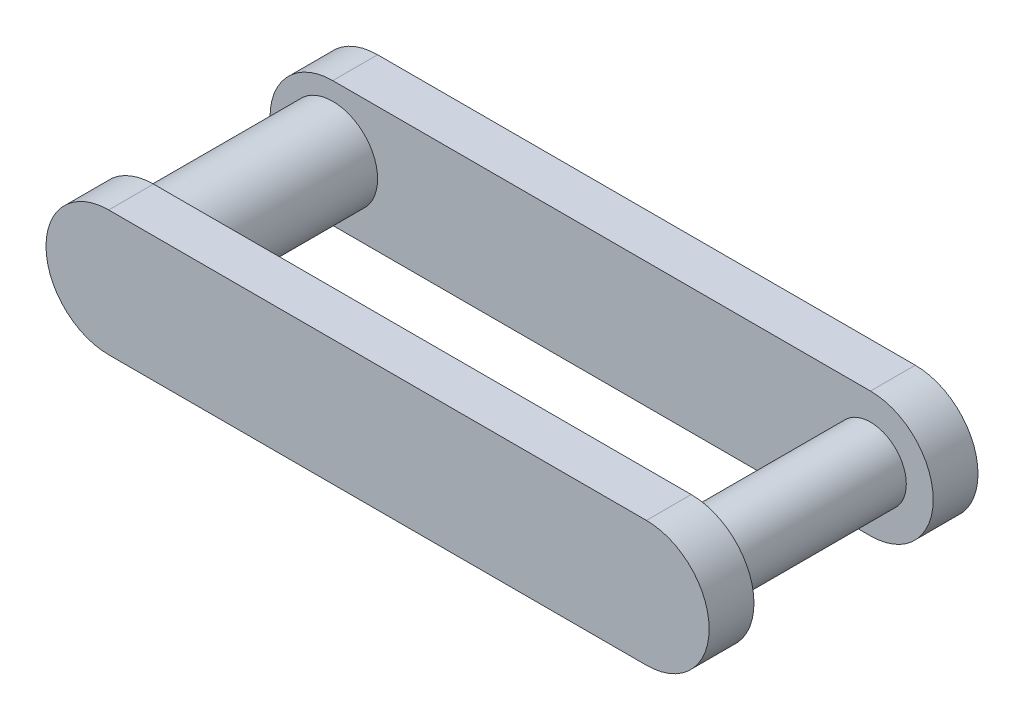
from build123d import *

# Parameters (mm, degrees)
SALIENTE_EXTRUIR1_DEPTH        = 10
SALIENTE_EXTRUIR1_DEPTH_BACK   = 10
CROQUIS1_R                     = 5
SALIENTE_EXTRUIR1_2_DEPTH      = 10
SALIENTE_EXTRUIR1_2_DEPTH_BACK = 10
CROQUIS1_R_2                   = 4
SALIENTE_EXTRUIR2_DEPTH        = 5


with BuildPart() as part:
    # Croquis1 → Saliente-Extruir1 (new, two sides: drawn at the far end of the back side and taken through both)
    with BuildSketch(Plane.XY.offset(-SALIENTE_EXTRUIR1_DEPTH_BACK)):
        with Locations((-30, 0)):
            Circle(CROQUIS1_R)
    extrude(amount=SALIENTE_EXTRUIR1_DEPTH + SALIENTE_EXTRUIR1_DEPTH_BACK)



with BuildPart() as body_2:
    # Croquis1 → Saliente-Extruir1 2 (new, two sides: drawn at the far end of the back side and taken through both)
    with BuildSketch(Plane.XY.offset(-SALIENTE_EXTRUIR1_2_DEPTH_BACK)):
        with Locations((30, 0)):
            Circle(CROQUIS1_R_2)
    extrude(amount=SALIENTE_EXTRUIR1_2_DEPTH + SALIENTE_EXTRUIR1_2_DEPTH_BACK)


with BuildPart() as part_1:
    add(part.part)

    add(body_2.part)  # Saliente-Extruir2 merges body 2
    # Croquis2 → Saliente-Extruir2 (add)
    with BuildSketch(Plane.XY.offset(10)):
        with BuildLine():
            Line((-30, 7), (30, 7))
            ThreePointArc((30, 7), (37, 0), (30, -7))
            Line((30, -7), (-30, -7))
            ThreePointArc((-30, -7), (-37, 0), (-30, 7))
        make_face()
    saliente_extruir2 = extrude(amount=SALIENTE_EXTRUIR2_DEPTH)

    # Simetría1: Saliente-Extruir2 across plane
    add(saliente_extruir2.mirror(Plane.XY))


solid = part_1.part
